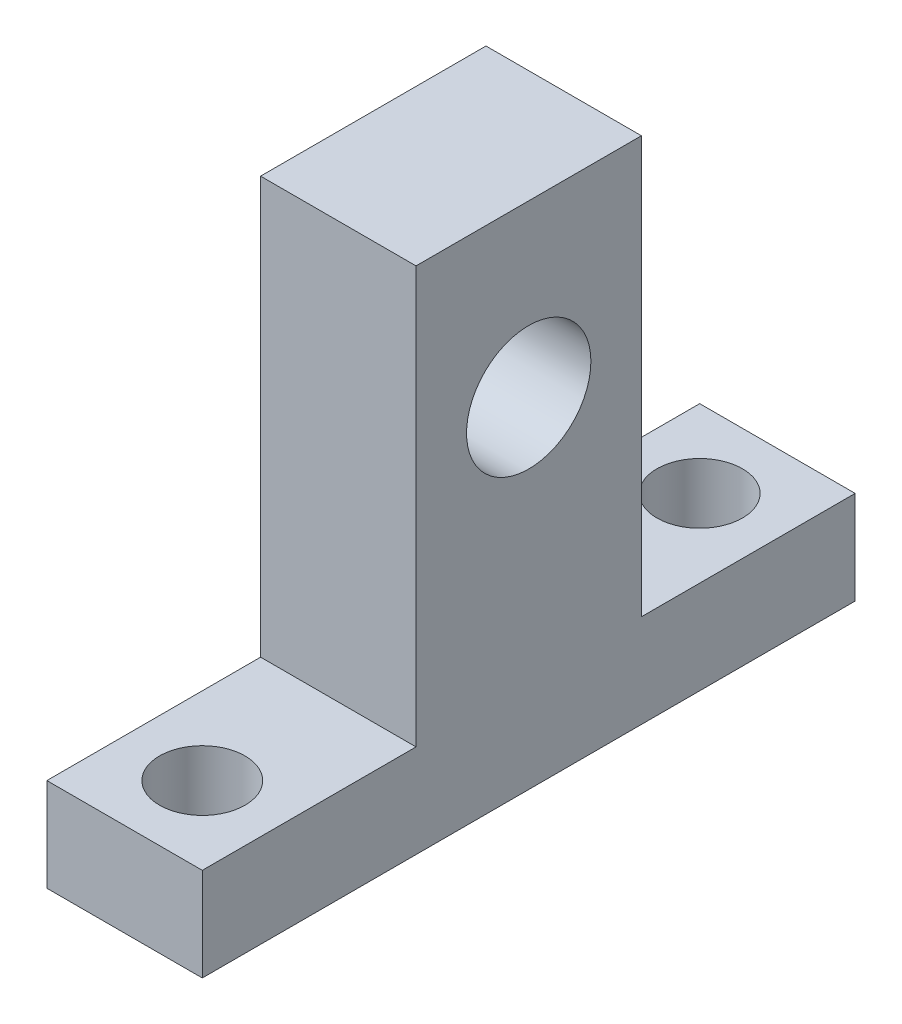
from build123d import *

# Parameters (mm, degrees)
SKETCH1_W             = 10
SKETCH1_H             = 13.75
SKETCH1_R             = 2.75
BOSS_EXTRUDE1_DEPTH   = 6
BOSS_EXTRUDE1_2_DEPTH = 6
SKETCH1_3_W           = 10
SKETCH1_3_H           = 14.5
BOSS_EXTRUDE2_DEPTH   = 32.8
SKETCH2_R             = 4
CUT_EXTRUDE1_DEPTH    = 32.8


with BuildPart() as part:
    # Sketch1 → Boss-Extrude1 (new body)
    with BuildSketch(Plane(origin=(0, 0, 0), x_dir=(1, 0, 0), z_dir=(0, 1, 0))):
        with Locations((0, 14.125)):
            Rectangle(SKETCH1_W, SKETCH1_H)
        with Locations((0, 16)):
            Circle(SKETCH1_R, mode=Mode.SUBTRACT)
    extrude(amount=BOSS_EXTRUDE1_DEPTH)



with BuildPart() as body_2:
    # Sketch1 → Boss-Extrude1 2 (new body)
    with BuildSketch(Plane(origin=(0, 0, 0), x_dir=(1, 0, 0), z_dir=(0, 1, 0))):
        with Locations((0, -14.125)):
            Rectangle(SKETCH1_W, SKETCH1_H)
        with Locations((0, -16)):
            Circle(SKETCH1_R, mode=Mode.SUBTRACT)
    extrude(amount=BOSS_EXTRUDE1_2_DEPTH)


with BuildPart() as part_1:
    add(part.part)

    add(body_2.part)  # Boss-Extrude2 merges body 2
    # Sketch1_3 → Boss-Extrude2 (add)
    with BuildSketch(Plane(origin=(0, 0, 0), x_dir=(1, 0, 0), z_dir=(0, 1, 0))):
        Rectangle(SKETCH1_3_W, SKETCH1_3_H)
    extrude(amount=BOSS_EXTRUDE2_DEPTH)

    # Sketch2 → Cut-Extrude1 (cut)
    with BuildSketch(Plane(origin=(5, 0, 0), x_dir=(0, 0, -1), z_dir=(1, 0, 0))):
        with Locations((0, 21.854969952)):
            Circle(SKETCH2_R)
    extrude(amount=-CUT_EXTRUDE1_DEPTH, mode=Mode.SUBTRACT)


solid = part_1.part
